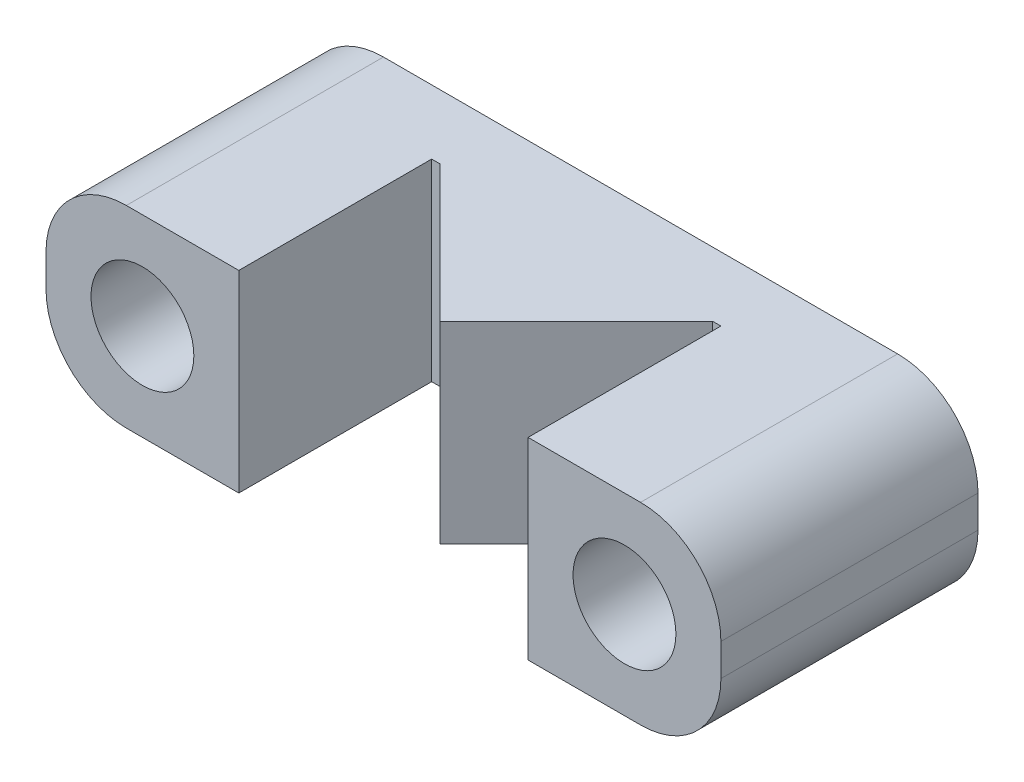
from build123d import *

# Parameters (mm, degrees)
SKETCH1_R           = 1.6
BOSS_EXTRUDE1_DEPTH = 8
SKETCH2_W           = 9
SKETCH2_H           = 8.199711987
CUT_EXTRUDE1_DEPTH  = 8
BOSS_EXTRUDE2_DEPTH = 6


with BuildPart() as part:
    # Sketch1 → Boss-Extrude1 (new body)
    with BuildSketch(Plane.XY):
        with BuildLine():
            Line((-0.5, 3), (15.5, 3))
            ThreePointArc((15.5, 3), (17.267766953, 2.267766953), (18, 0.5))
            Line((18, 0.5), (18, -0.5))
            ThreePointArc((18, -0.5), (17.267766953, -2.267766953), (15.5, -3))
            Line((15.5, -3), (-0.5, -3))
            ThreePointArc((-0.5, -3), (-2.267766953, -2.267766953), (-3, -0.5))
            Line((-3, -0.5), (-3, 0.5))
            ThreePointArc((-3, 0.5), (-2.267766953, 2.267766953), (-0.5, 3))
        make_face()
        Circle(SKETCH1_R, mode=Mode.SUBTRACT)
        with Locations((15, 0)):
            Circle(SKETCH1_R, mode=Mode.SUBTRACT)
    extrude(amount=BOSS_EXTRUDE1_DEPTH)

    # Sketch2 → Cut-Extrude1 (cut)
    with BuildSketch(Plane.XZ.offset(3)):
        with Locations((7.5, 6.099855994)):
            Rectangle(SKETCH2_W, SKETCH2_H)
    extrude(amount=-CUT_EXTRUDE1_DEPTH, mode=Mode.SUBTRACT)

    # Sketch3 → Boss-Extrude2 (add)
    with BuildSketch(Plane.XZ.offset(3)):
        Polygon((3.257359313, 2), (7.5, 6.242640687), (11.742640687, 2), align=None)
    extrude(amount=-BOSS_EXTRUDE2_DEPTH)


solid = part.part
